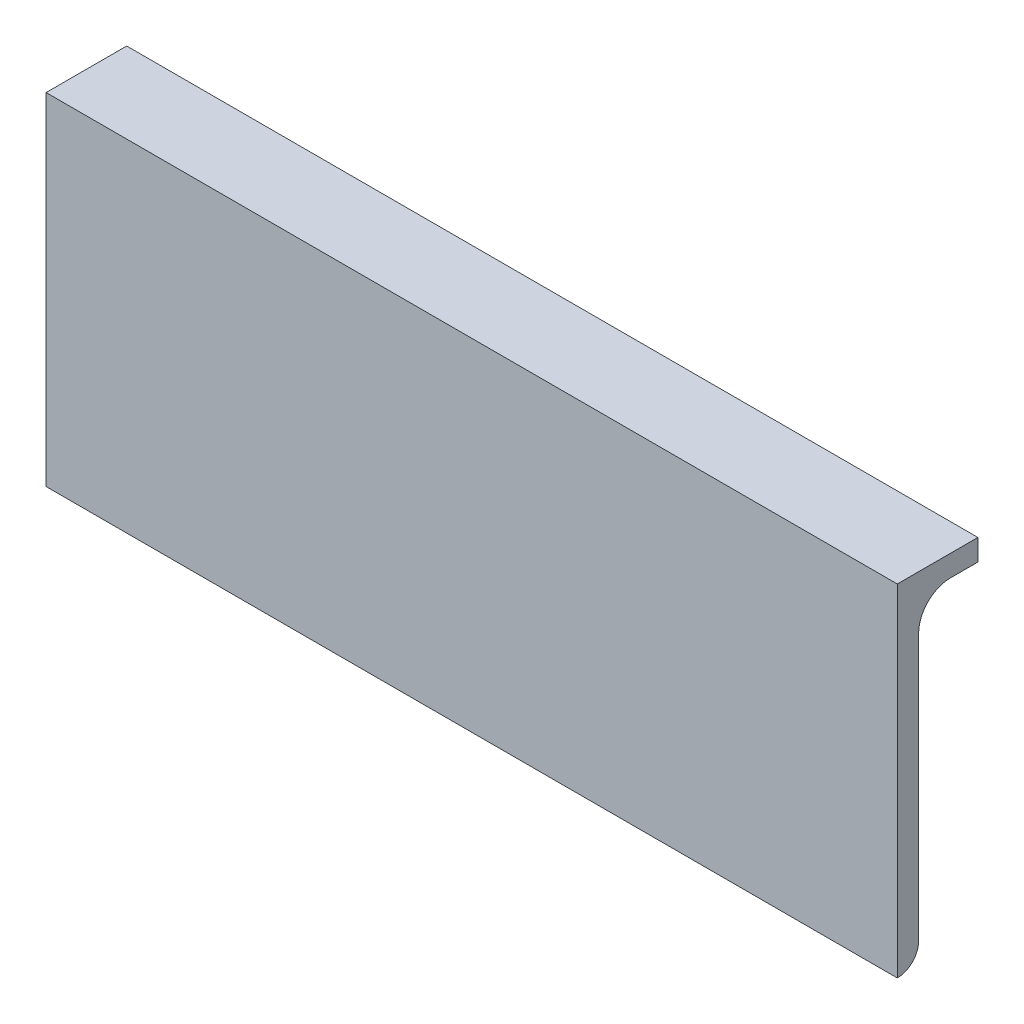
from build123d import *

# Parameters (mm, degrees)
HIERRO_ANGULAR_2_X_2_X_0_125_1_DEPTH = 126.72
CROQUIS3_W                           = 126.72
CROQUIS3_H                           = 38.8
CORTAR_EXTRUIR1_DEPTH                = 3.175


with BuildPart() as part:
    # Sketch1 → Hierro angular 2 X 2 X 0.125(1) (new body)
    with BuildSketch(Plane(origin=(-63.36, 0, 0), x_dir=(0, -1, 0), z_dir=(1, 0, 0))):
        with BuildLine():
            Line((0, 0), (0, 50.8))
            Line((0, 50.8), (0.00508, 50.8))
            ThreePointArc((0.00508, 50.8), (2.246551928, 49.871551928), (3.175, 47.63008))
            Line((3.175, 47.63008), (3.175, 7.9375))
            ThreePointArc((3.175, 7.9375), (4.569903955, 4.569903955), (7.9375, 3.175))
            Line((7.9375, 3.175), (47.63008, 3.175))
            ThreePointArc((47.63008, 3.175), (49.871551928, 2.246551928), (50.8, 0.00508))
            Line((50.8, 0.00508), (50.8, 0))
            Line((50.8, 0), (0, 0))
        make_face()
    extrude(amount=HIERRO_ANGULAR_2_X_2_X_0_125_1_DEPTH)

    # Croquis3 → Cortar-Extruir1 (cut)
    with BuildSketch(Plane(origin=(0, 0, 0), x_dir=(1, 0, 0), z_dir=(0, 1, 0))):
        with Locations((0, 31.4)):
            Rectangle(CROQUIS3_W, CROQUIS3_H)
    extrude(amount=-CORTAR_EXTRUIR1_DEPTH, mode=Mode.SUBTRACT)


solid = part.part
